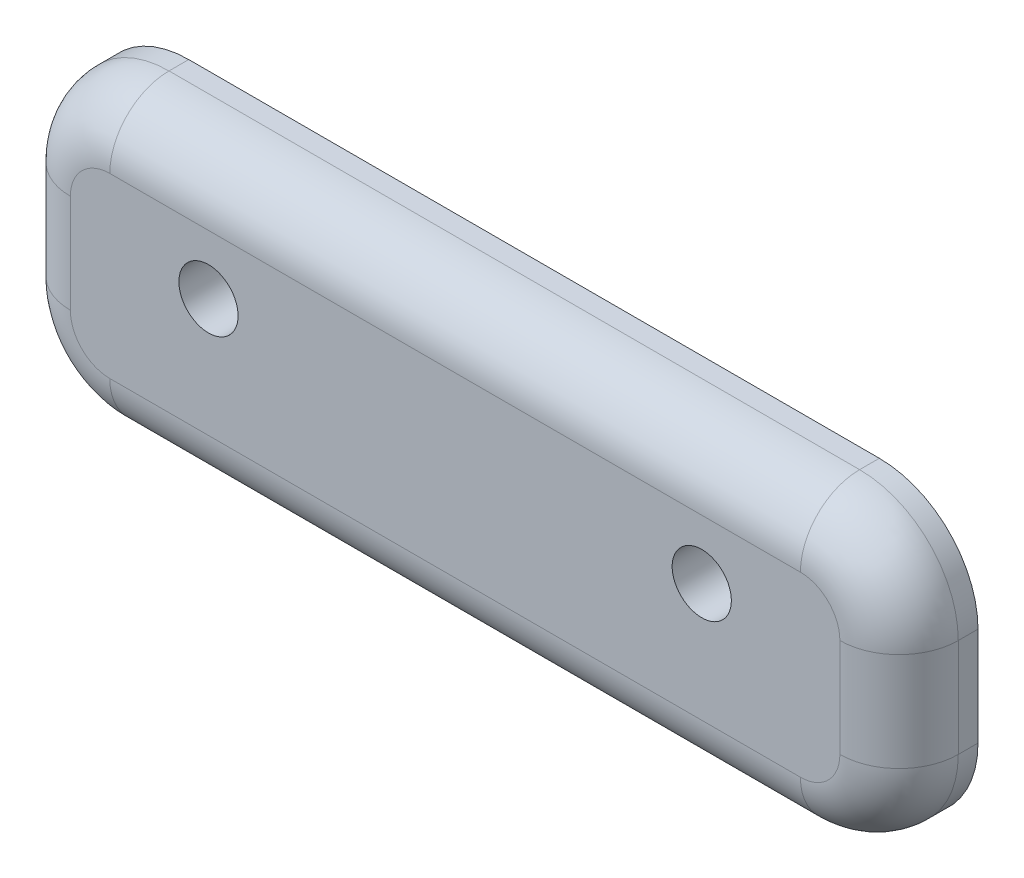
from build123d import *

# Parameters (mm, degrees)
ESQUISSE1_W             = 45
ESQUISSE1_H             = 15
BOSS_EXTRU_1_DEPTH      = 4
CONG_1_R                = 5
CONG_2_R                = 3
ESQUISSE2_R             = 1.5
ENL_V_MAT_EXTRU_1_DEPTH = 5


with BuildPart() as part:
    # Esquisse1 → Boss.-Extru.1 (new body)
    with BuildSketch(Plane.XY):
        Rectangle(ESQUISSE1_W, ESQUISSE1_H)
    extrude(amount=BOSS_EXTRU_1_DEPTH)

    # Congé1
    cong_1_edges = [part.edges().sort_by_distance(p)[0] for p in [
        (-22.5, 7.5, 2),
        (22.5, 7.5, 2),
        (22.5, -7.5, 2),
        (-22.5, -7.5, 2),
    ]]
    fillet(cong_1_edges, radius=CONG_1_R)

    # Congé2
    cong_2_edges = [part.edges().sort_by_distance(p)[0] for p in [
        (22.5, 0, 4),
        (0, -7.5, 4),
        (-22.5, 0, 4),
        (0, 7.5, 4),
        (21.035533906, 6.035533906, 4),
        (-21.035533906, 6.035533906, 4),
        (-21.035533906, -6.035533906, 4),
        (21.035533906, -6.035533906, 4),
    ]]
    fillet(cong_2_edges, radius=CONG_2_R)

    # Esquisse2 → Enlèv. mat.-Extru.1 (cut, through all)
    with BuildSketch(Plane.XY.offset(4)):
        with Locations((-12.5, 1.5)):
            Circle(ESQUISSE2_R)
        with Locations((12.5, 1.5)):
            Circle(ESQUISSE2_R)
    extrude(amount=-ENL_V_MAT_EXTRU_1_DEPTH, mode=Mode.SUBTRACT)


solid = part.part
